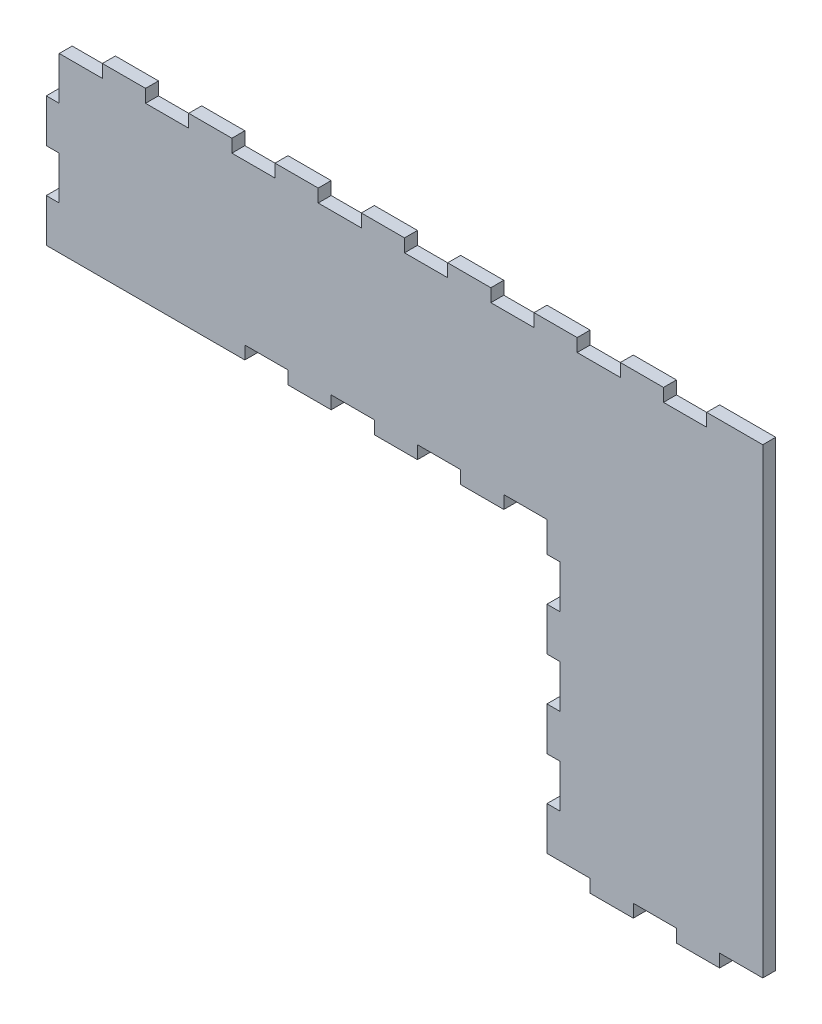
from build123d import *

# Parameters (mm, degrees)
BOSS_EXTRU_1_DEPTH         = 3
ESQUISSE2_W                = 10
ESQUISSE2_H                = 3
ENL_V_MAT_EXTRU_1_DEPTH    = 3
R_P_TITION_LIN_AIRE1_COUNT = 8
R_P_TITION_LIN_AIRE1_PITCH = 20
ESQUISSE4_W                = 3
ESQUISSE4_H                = 10
BOSS_EXTRU_2_DEPTH         = 3
R_P_TITION_LIN_AIRE3_COUNT = 2
R_P_TITION_LIN_AIRE3_PITCH = 20
ESQUISSE5_W                = 10
ESQUISSE5_H                = 3
ENL_V_MAT_EXTRU_3_DEPTH    = 3
R_P_TITION_LIN_AIRE4_COUNT = 4
R_P_TITION_LIN_AIRE4_PITCH = 20
ESQUISSE6_W                = 10
ESQUISSE6_H                = 3
ENL_V_MAT_EXTRU_4_DEPTH    = 3
R_P_TITION_LIN_AIRE5_COUNT = 3
R_P_TITION_LIN_AIRE5_PITCH = 20
ESQUISSE7_W                = 3
ESQUISSE7_H                = 10
ENL_V_MAT_EXTRU_5_DEPTH    = 3
R_P_TITION_LIN_AIRE6_COUNT = 3
R_P_TITION_LIN_AIRE6_PITCH = 20


with BuildPart() as part:
    # Esquisse1 → Boss.-Extru.1 (new body)
    with BuildSketch(Plane.XY):
        Polygon((163, 0), (163, -110), (113, -110), (113, -43), (0, -43), (0, 0), align=None)
    extrude(amount=BOSS_EXTRU_1_DEPTH)

    # Esquisse2 → Enlèv. mat.-Extru.1 (cut)
    with BuildSketch(Plane.XY.offset(3)):
        with Locations((5, -1.5)):
            Rectangle(ESQUISSE2_W, ESQUISSE2_H)
    enl_v_mat_extru_1 = extrude(amount=-ENL_V_MAT_EXTRU_1_DEPTH, mode=Mode.SUBTRACT)

    # Répétition linéaire1: Enlèv. mat.-Extru.1 ×8
    with Locations(*[(i * R_P_TITION_LIN_AIRE1_PITCH, 0, 0) for i in range(1, R_P_TITION_LIN_AIRE1_COUNT)]):
        add(enl_v_mat_extru_1, mode=Mode.SUBTRACT)

    # Esquisse4 → Boss.-Extru.2 (add)
    with BuildSketch(Plane.ZY):
        with Locations((1.5, -38)):
            Rectangle(ESQUISSE4_W, ESQUISSE4_H)
    boss_extru_2 = extrude(amount=BOSS_EXTRU_2_DEPTH)

    # Répétition linéaire3: Boss.-Extru.2 ×2
    with Locations(*[(0, i * R_P_TITION_LIN_AIRE3_PITCH, 0) for i in range(1, R_P_TITION_LIN_AIRE3_COUNT)]):
        add(boss_extru_2)

    # Esquisse5 → Enlèv. mat.-Extru.3 (cut)
    with BuildSketch(Plane.XY.offset(3)):
        with Locations((108, -41.5)):
            Rectangle(ESQUISSE5_W, ESQUISSE5_H)
    enl_v_mat_extru_3 = extrude(amount=-ENL_V_MAT_EXTRU_3_DEPTH, mode=Mode.SUBTRACT)

    # Répétition linéaire4: Enlèv. mat.-Extru.3 ×4
    with Locations(*[(-i * R_P_TITION_LIN_AIRE4_PITCH, 0, 0) for i in range(1, R_P_TITION_LIN_AIRE4_COUNT)]):
        add(enl_v_mat_extru_3, mode=Mode.SUBTRACT)

    # Esquisse6 → Enlèv. mat.-Extru.4 (cut)
    with BuildSketch(Plane.XY.offset(3)):
        with Locations((118, -108.5)):
            Rectangle(ESQUISSE6_W, ESQUISSE6_H)
    enl_v_mat_extru_4 = extrude(amount=-ENL_V_MAT_EXTRU_4_DEPTH, mode=Mode.SUBTRACT)

    # Répétition linéaire5: Enlèv. mat.-Extru.4 ×3
    with Locations(*[(i * R_P_TITION_LIN_AIRE5_PITCH, 0, 0) for i in range(1, R_P_TITION_LIN_AIRE5_COUNT)]):
        add(enl_v_mat_extru_4, mode=Mode.SUBTRACT)

    # Esquisse7 → Enlèv. mat.-Extru.5 (cut)
    with BuildSketch(Plane.XY.offset(3)):
        with Locations((114.5, -92)):
            Rectangle(ESQUISSE7_W, ESQUISSE7_H)
    enl_v_mat_extru_5 = extrude(amount=-ENL_V_MAT_EXTRU_5_DEPTH, mode=Mode.SUBTRACT)

    # Répétition linéaire6: Enlèv. mat.-Extru.5 ×3
    with Locations(*[(0, i * R_P_TITION_LIN_AIRE6_PITCH, 0) for i in range(1, R_P_TITION_LIN_AIRE6_COUNT)]):
        add(enl_v_mat_extru_5, mode=Mode.SUBTRACT)


solid = part.part
